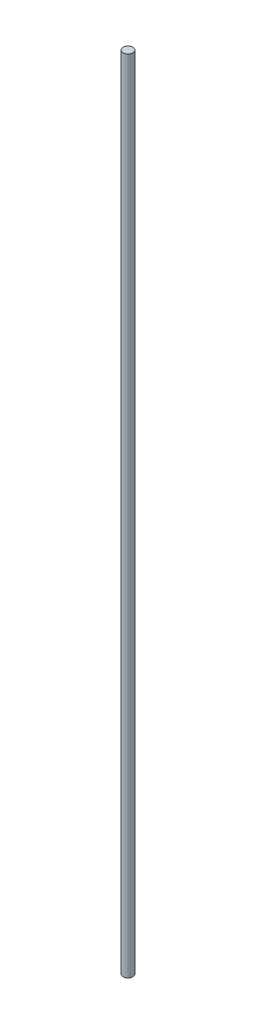
from build123d import *

# Parameters (mm, degrees)
SKETCH1_R           = 1.5
BOSS_EXTRUDE1_DEPTH = 245


with BuildPart() as part:
    # Sketch1 → Boss-Extrude1 (new body)
    with BuildSketch(Plane(origin=(0, 0, 0), x_dir=(1, 0, 0), z_dir=(0, 1, 0))):
        Circle(SKETCH1_R)
    extrude(amount=BOSS_EXTRUDE1_DEPTH)


solid = part.part
